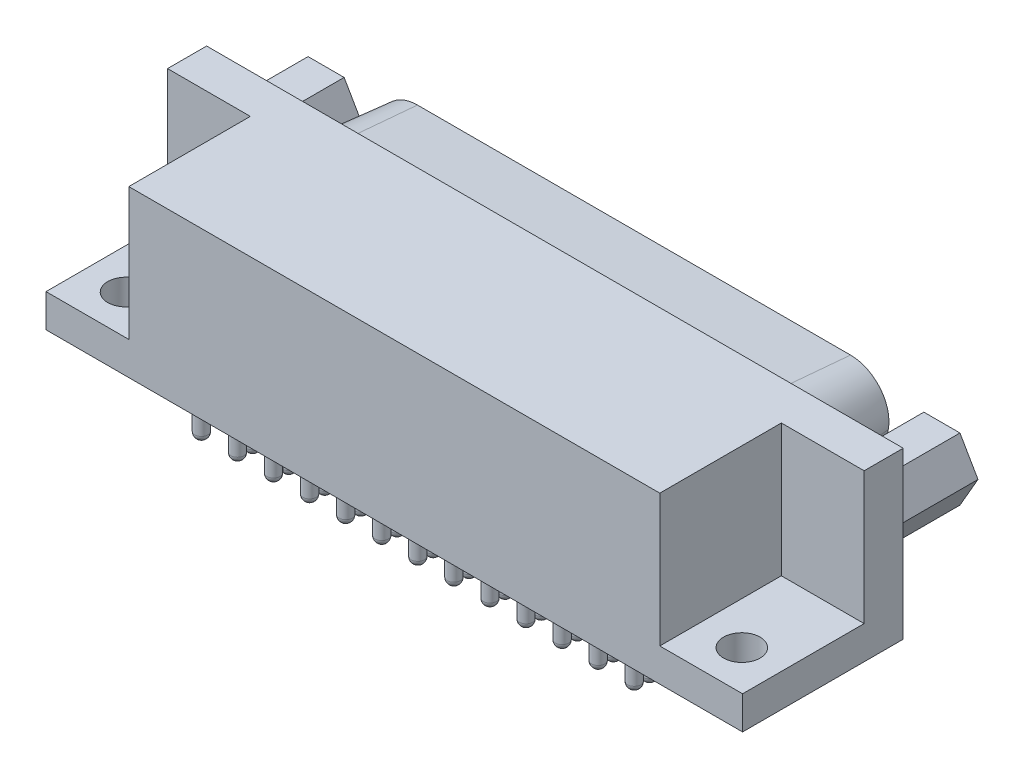
from build123d import *

# Parameters (mm, degrees)
SKETCH1_W                     = 53.47
SKETCH1_H                     = 12.33
BASE_EXTRUDE_DEPTH            = 12.7
BOSS_EXTRUDE1_DEPTH           = 6.07
BOSS_EXTRUDE1_TAPER           = 5
CUT_EXTRUDE5_DEPTH            = 6.07
CUT_EXTRUDE5_DRAFT            = 5
SKETCH6_R                     = 0.5
BOSS_EXTRUDE2_DEPTH           = 2.54
DOME3_FACE_RADIUS             = 0.5
DOME3_HEIGHT                  = 0.5
LPATTERN1_COUNT               = 13
LPATTERN1_PITCH               = 2.7686
LPATTERN1_COPY_1_FACE_RADIUS  = 0.5
LPATTERN1_COPY_1_HEIGHT       = 0.5
LPATTERN1_COPY_2_FACE_RADIUS  = 0.5
LPATTERN1_COPY_2_HEIGHT       = 0.5
LPATTERN1_COPY_3_FACE_RADIUS  = 0.5
LPATTERN1_COPY_3_HEIGHT       = 0.5
LPATTERN1_COPY_4_FACE_RADIUS  = 0.5
LPATTERN1_COPY_4_HEIGHT       = 0.5
LPATTERN1_COPY_5_FACE_RADIUS  = 0.5
LPATTERN1_COPY_5_HEIGHT       = 0.5
LPATTERN1_COPY_6_FACE_RADIUS  = 0.5
LPATTERN1_COPY_6_HEIGHT       = 0.5
LPATTERN1_COPY_7_FACE_RADIUS  = 0.5
LPATTERN1_COPY_7_HEIGHT       = 0.5
LPATTERN1_COPY_8_FACE_RADIUS  = 0.5
LPATTERN1_COPY_8_HEIGHT       = 0.5
LPATTERN1_COPY_9_FACE_RADIUS  = 0.5
LPATTERN1_COPY_9_HEIGHT       = 0.5
LPATTERN1_COPY_10_FACE_RADIUS = 0.5
LPATTERN1_COPY_10_HEIGHT      = 0.5
LPATTERN1_COPY_11_FACE_RADIUS = 0.5
LPATTERN1_COPY_11_HEIGHT      = 0.5
LPATTERN1_COPY_12_FACE_RADIUS = 0.5
LPATTERN1_COPY_12_HEIGHT      = 0.5
SKETCH7_R                     = 0.5
BOSS_EXTRUDE3_DEPTH           = 4
DOME4_FACE_RADIUS             = 0.5
DOME4_HEIGHT                  = 0.5
LPATTERN4_COUNT               = 12
LPATTERN4_PITCH               = 2.7686
LPATTERN4_COPY_1_FACE_RADIUS  = 0.5
LPATTERN4_COPY_1_HEIGHT       = 0.5
LPATTERN4_COPY_2_FACE_RADIUS  = 0.5
LPATTERN4_COPY_2_HEIGHT       = 0.5
LPATTERN4_COPY_3_FACE_RADIUS  = 0.5
LPATTERN4_COPY_3_HEIGHT       = 0.5
LPATTERN4_COPY_4_FACE_RADIUS  = 0.5
LPATTERN4_COPY_4_HEIGHT       = 0.5
LPATTERN4_COPY_5_FACE_RADIUS  = 0.5
LPATTERN4_COPY_5_HEIGHT       = 0.5
LPATTERN4_COPY_6_FACE_RADIUS  = 0.5
LPATTERN4_COPY_6_HEIGHT       = 0.5
LPATTERN4_COPY_7_FACE_RADIUS  = 0.5
LPATTERN4_COPY_7_HEIGHT       = 0.5
LPATTERN4_COPY_8_FACE_RADIUS  = 0.5
LPATTERN4_COPY_8_HEIGHT       = 0.5
LPATTERN4_COPY_9_FACE_RADIUS  = 0.5
LPATTERN4_COPY_9_HEIGHT       = 0.5
LPATTERN4_COPY_10_FACE_RADIUS = 0.5
LPATTERN4_COPY_10_HEIGHT      = 0.5
LPATTERN4_COPY_11_FACE_RADIUS = 0.5
LPATTERN4_COPY_11_HEIGHT      = 0.5
SKETCH14_R                    = 0.5
BOSS_EXTRUDE5_DEPTH           = 4
DOME1_FACE_RADIUS             = 0.5
DOME1_HEIGHT                  = 0.5
LPATTERN5_COUNT               = 13
LPATTERN5_PITCH               = 2.77
LPATTERN5_COPY_1_FACE_RADIUS  = 0.5
LPATTERN5_COPY_1_HEIGHT       = 0.5
LPATTERN5_COPY_2_FACE_RADIUS  = 0.5
LPATTERN5_COPY_2_HEIGHT       = 0.5
LPATTERN5_COPY_3_FACE_RADIUS  = 0.5
LPATTERN5_COPY_3_HEIGHT       = 0.5
LPATTERN5_COPY_4_FACE_RADIUS  = 0.5
LPATTERN5_COPY_4_HEIGHT       = 0.5
LPATTERN5_COPY_5_FACE_RADIUS  = 0.5
LPATTERN5_COPY_5_HEIGHT       = 0.5
LPATTERN5_COPY_6_FACE_RADIUS  = 0.5
LPATTERN5_COPY_6_HEIGHT       = 0.5
LPATTERN5_COPY_7_FACE_RADIUS  = 0.5
LPATTERN5_COPY_7_HEIGHT       = 0.5
LPATTERN5_COPY_8_FACE_RADIUS  = 0.5
LPATTERN5_COPY_8_HEIGHT       = 0.5
LPATTERN5_COPY_9_FACE_RADIUS  = 0.5
LPATTERN5_COPY_9_HEIGHT       = 0.5
LPATTERN5_COPY_10_FACE_RADIUS = 0.5
LPATTERN5_COPY_10_HEIGHT      = 0.5
LPATTERN5_COPY_11_FACE_RADIUS = 0.5
LPATTERN5_COPY_11_HEIGHT      = 0.5
LPATTERN5_COPY_12_FACE_RADIUS = 0.5
LPATTERN5_COPY_12_HEIGHT      = 0.5
SKETCH15_R                    = 0.5
BOSS_EXTRUDE6_DEPTH           = 4
DOME2_FACE_RADIUS             = 0.5
DOME2_HEIGHT                  = 0.5
LPATTERN6_COUNT               = 12
LPATTERN6_PITCH               = 2.77
LPATTERN6_COPY_1_FACE_RADIUS  = 0.5
LPATTERN6_COPY_1_HEIGHT       = 0.5
LPATTERN6_COPY_2_FACE_RADIUS  = 0.5
LPATTERN6_COPY_2_HEIGHT       = 0.5
LPATTERN6_COPY_3_FACE_RADIUS  = 0.5
LPATTERN6_COPY_3_HEIGHT       = 0.5
LPATTERN6_COPY_4_FACE_RADIUS  = 0.5
LPATTERN6_COPY_4_HEIGHT       = 0.5
LPATTERN6_COPY_5_FACE_RADIUS  = 0.5
LPATTERN6_COPY_5_HEIGHT       = 0.5
LPATTERN6_COPY_6_FACE_RADIUS  = 0.5
LPATTERN6_COPY_6_HEIGHT       = 0.5
LPATTERN6_COPY_7_FACE_RADIUS  = 0.5
LPATTERN6_COPY_7_HEIGHT       = 0.5
LPATTERN6_COPY_8_FACE_RADIUS  = 0.5
LPATTERN6_COPY_8_HEIGHT       = 0.5
LPATTERN6_COPY_9_FACE_RADIUS  = 0.5
LPATTERN6_COPY_9_HEIGHT       = 0.5
LPATTERN6_COPY_10_FACE_RADIUS = 0.5
LPATTERN6_COPY_10_HEIGHT      = 0.5
LPATTERN6_COPY_11_FACE_RADIUS = 0.5
LPATTERN6_COPY_11_HEIGHT      = 0.5
SKETCH12_R                    = 1.304277921
BOSS_EXTRUDE4_DEPTH           = 6.07
SKETCH9_W                     = 6.35508
SKETCH9_H                     = 10.16
CUT_EXTRUDE3_DEPTH            = 9.33
SKETCH11_R                    = 1.4
CUT_EXTRUDE4_DEPTH            = 48.492511024


with BuildPart() as part:
    # Sketch1 → Base-Extrude (new body)
    with BuildSketch(Plane(origin=(0, 0, 0), x_dir=(1, 0, 0), z_dir=(0, 1, 0))):
        with Locations((16.575, 4.395)):
            Rectangle(SKETCH1_W, SKETCH1_H)
    extrude(amount=BASE_EXTRUDE_DEPTH)

    # Sketch2 → Boss-Extrude1 (add)
    with BuildSketch(Plane(origin=(0, 0, -10.56), x_dir=(-1, 0, 0), z_dir=(0, 0, -1))):
        with BuildLine():
            Line((-32.614575524, 1.37), (-0.535424476, 1.37))
            ThreePointArc((-0.535424476, 1.37), (1.679299183, 2.16571255), (2.881216284, 4.188966026))
            Line((2.881216284, 4.188966026), (3.46164076, 7.188966026))
            ThreePointArc((3.46164076, 7.188966026), (2.72928745, 10.064723659), (0.045, 11.33))
            Line((0.045, 11.33), (-33.195, 11.33))
            ThreePointArc((-33.195, 11.33), (-35.87928745, 10.064723659), (-36.61164076, 7.188966026))
            Line((-36.61164076, 7.188966026), (-36.031216284, 4.188966026))
            ThreePointArc((-36.031216284, 4.188966026), (-34.829299183, 2.16571255), (-32.614575524, 1.37))
        make_face()
    extrude(amount=BOSS_EXTRUDE1_DEPTH, taper=BOSS_EXTRUDE1_TAPER)


with BuildPart() as cut_extrude5_tool:
    # Sketch13 → Cut-Extrude5 (with draft: the straight prism first)
    with BuildSketch(Plane(origin=(0, 0, -16.63), x_dir=(-1, 0, 0), z_dir=(0, 0, -1))):
        with BuildLine():
            Line((1.967111537, 4.365822282), (2.547536013, 7.365822282))
            ThreePointArc((2.547536013, 7.365822282), (2.011120082, 9.47218568), (0.045, 10.398943812))
            Line((0.045, 10.398943812), (-33.195, 10.398943812))
            ThreePointArc((-33.195, 10.398943812), (-35.161120082, 9.47218568), (-35.697536013, 7.365822282))
            Line((-35.697536013, 7.365822282), (-35.117111537, 4.365822282))
            ThreePointArc((-35.117111537, 4.365822282), (-34.236761204, 2.883879918), (-32.614575524, 2.301056188))
            Line((-32.614575524, 2.301056188), (-0.535424476, 2.301056188))
            ThreePointArc((-0.535424476, 2.301056188), (1.086761204, 2.883879918), (1.967111537, 4.365822282))
        make_face()
    extrude(amount=-CUT_EXTRUDE5_DEPTH)
    # Cut-Extrude5: the draft: its side faces are tilted about the plane it starts from
    cut_extrude5_sides = [cut_extrude5_tool.faces().sort_by_distance(p)[0] for p in [
        (16.575, 2.301056188, -13.595),
        (-1.086761204, 2.883879918, -13.595),
        (-2.257323775, 5.865822282, -13.595),
        (-2.011120082, 9.47218568, -13.595),
        (16.575, 10.398943812, -13.595),
        (35.161120082, 9.47218568, -13.595),
        (35.407323775, 5.865822282, -13.595),
        (34.236761204, 2.883879918, -13.595),
    ]]
    draft(cut_extrude5_sides, Plane(origin=(0, 0, -16.63), x_dir=(-1, 0, 0), z_dir=(0, 0, -1)), CUT_EXTRUDE5_DRAFT)


with BuildPart() as part_1:
    add(part.part)

    # Cut-Extrude5: cut by cut_extrude5_tool
    add(cut_extrude5_tool.part, mode=Mode.SUBTRACT)

    # Sketch6 → Boss-Extrude2 (add)
    with BuildSketch(Plane.XZ):
        with Locations(Location((0, 0, 0), (0, 0, 270))):
            Circle(SKETCH6_R)
    boss_extrude2 = extrude(amount=BOSS_EXTRUDE2_DEPTH)

    # Dome3: a dome of height H over a round flat face of radius A is a cap of a sphere of radius (A * A + H * H) / (2 * H)
    dome3_r = (DOME3_FACE_RADIUS * DOME3_FACE_RADIUS + DOME3_HEIGHT * DOME3_HEIGHT) / (2 * DOME3_HEIGHT)
    dome3_base = Plane((0, -2.54, 0), z_dir=(0, -1, 0))
    with Locations(dome3_base.offset(DOME3_HEIGHT - dome3_r)):
        dome3_ball = Sphere(dome3_r, mode=Mode.PRIVATE)
    add(split(dome3_ball, bisect_by=dome3_base, keep=Keep.TOP, mode=Mode.PRIVATE))

    # LPattern1: Boss-Extrude2 ×13
    with Locations(*[(i * LPATTERN1_PITCH, 0, 0) for i in range(1, LPATTERN1_COUNT)]):
        add(boss_extrude2)

    # LPattern1 copy 1: a dome of height H over a round flat face of radius A is a cap of a sphere of radius (A * A + H * H) / (2 * H)
    lpattern1_copy_1_r = (LPATTERN1_COPY_1_FACE_RADIUS * LPATTERN1_COPY_1_FACE_RADIUS + LPATTERN1_COPY_1_HEIGHT * LPATTERN1_COPY_1_HEIGHT) / (2 * LPATTERN1_COPY_1_HEIGHT)
    lpattern1_copy_1_base = Plane((2.7686, -2.54, 0), z_dir=(0, -1, 0))
    with Locations(lpattern1_copy_1_base.offset(LPATTERN1_COPY_1_HEIGHT - lpattern1_copy_1_r)):
        lpattern1_copy_1_ball = Sphere(lpattern1_copy_1_r, mode=Mode.PRIVATE)
    add(split(lpattern1_copy_1_ball, bisect_by=lpattern1_copy_1_base, keep=Keep.TOP, mode=Mode.PRIVATE))

    # LPattern1 copy 2: a dome of height H over a round flat face of radius A is a cap of a sphere of radius (A * A + H * H) / (2 * H)
    lpattern1_copy_2_r = (LPATTERN1_COPY_2_FACE_RADIUS * LPATTERN1_COPY_2_FACE_RADIUS + LPATTERN1_COPY_2_HEIGHT * LPATTERN1_COPY_2_HEIGHT) / (2 * LPATTERN1_COPY_2_HEIGHT)
    lpattern1_copy_2_base = Plane((5.5372, -2.54, 0), z_dir=(0, -1, 0))
    with Locations(lpattern1_copy_2_base.offset(LPATTERN1_COPY_2_HEIGHT - lpattern1_copy_2_r)):
        lpattern1_copy_2_ball = Sphere(lpattern1_copy_2_r, mode=Mode.PRIVATE)
    add(split(lpattern1_copy_2_ball, bisect_by=lpattern1_copy_2_base, keep=Keep.TOP, mode=Mode.PRIVATE))

    # LPattern1 copy 3: a dome of height H over a round flat face of radius A is a cap of a sphere of radius (A * A + H * H) / (2 * H)
    lpattern1_copy_3_r = (LPATTERN1_COPY_3_FACE_RADIUS * LPATTERN1_COPY_3_FACE_RADIUS + LPATTERN1_COPY_3_HEIGHT * LPATTERN1_COPY_3_HEIGHT) / (2 * LPATTERN1_COPY_3_HEIGHT)
    lpattern1_copy_3_base = Plane((8.3058, -2.54, 0), z_dir=(0, -1, 0))
    with Locations(lpattern1_copy_3_base.offset(LPATTERN1_COPY_3_HEIGHT - lpattern1_copy_3_r)):
        lpattern1_copy_3_ball = Sphere(lpattern1_copy_3_r, mode=Mode.PRIVATE)
    add(split(lpattern1_copy_3_ball, bisect_by=lpattern1_copy_3_base, keep=Keep.TOP, mode=Mode.PRIVATE))

    # LPattern1 copy 4: a dome of height H over a round flat face of radius A is a cap of a sphere of radius (A * A + H * H) / (2 * H)
    lpattern1_copy_4_r = (LPATTERN1_COPY_4_FACE_RADIUS * LPATTERN1_COPY_4_FACE_RADIUS + LPATTERN1_COPY_4_HEIGHT * LPATTERN1_COPY_4_HEIGHT) / (2 * LPATTERN1_COPY_4_HEIGHT)
    lpattern1_copy_4_base = Plane((11.0744, -2.54, 0), z_dir=(0, -1, 0))
    with Locations(lpattern1_copy_4_base.offset(LPATTERN1_COPY_4_HEIGHT - lpattern1_copy_4_r)):
        lpattern1_copy_4_ball = Sphere(lpattern1_copy_4_r, mode=Mode.PRIVATE)
    add(split(lpattern1_copy_4_ball, bisect_by=lpattern1_copy_4_base, keep=Keep.TOP, mode=Mode.PRIVATE))

    # LPattern1 copy 5: a dome of height H over a round flat face of radius A is a cap of a sphere of radius (A * A + H * H) / (2 * H)
    lpattern1_copy_5_r = (LPATTERN1_COPY_5_FACE_RADIUS * LPATTERN1_COPY_5_FACE_RADIUS + LPATTERN1_COPY_5_HEIGHT * LPATTERN1_COPY_5_HEIGHT) / (2 * LPATTERN1_COPY_5_HEIGHT)
    lpattern1_copy_5_base = Plane((13.843, -2.54, 0), z_dir=(0, -1, 0))
    with Locations(lpattern1_copy_5_base.offset(LPATTERN1_COPY_5_HEIGHT - lpattern1_copy_5_r)):
        lpattern1_copy_5_ball = Sphere(lpattern1_copy_5_r, mode=Mode.PRIVATE)
    add(split(lpattern1_copy_5_ball, bisect_by=lpattern1_copy_5_base, keep=Keep.TOP, mode=Mode.PRIVATE))

    # LPattern1 copy 6: a dome of height H over a round flat face of radius A is a cap of a sphere of radius (A * A + H * H) / (2 * H)
    lpattern1_copy_6_r = (LPATTERN1_COPY_6_FACE_RADIUS * LPATTERN1_COPY_6_FACE_RADIUS + LPATTERN1_COPY_6_HEIGHT * LPATTERN1_COPY_6_HEIGHT) / (2 * LPATTERN1_COPY_6_HEIGHT)
    lpattern1_copy_6_base = Plane((16.6116, -2.54, 0), z_dir=(0, -1, 0))
    with Locations(lpattern1_copy_6_base.offset(LPATTERN1_COPY_6_HEIGHT - lpattern1_copy_6_r)):
        lpattern1_copy_6_ball = Sphere(lpattern1_copy_6_r, mode=Mode.PRIVATE)
    add(split(lpattern1_copy_6_ball, bisect_by=lpattern1_copy_6_base, keep=Keep.TOP, mode=Mode.PRIVATE))

    # LPattern1 copy 7: a dome of height H over a round flat face of radius A is a cap of a sphere of radius (A * A + H * H) / (2 * H)
    lpattern1_copy_7_r = (LPATTERN1_COPY_7_FACE_RADIUS * LPATTERN1_COPY_7_FACE_RADIUS + LPATTERN1_COPY_7_HEIGHT * LPATTERN1_COPY_7_HEIGHT) / (2 * LPATTERN1_COPY_7_HEIGHT)
    lpattern1_copy_7_base = Plane((19.3802, -2.54, 0), z_dir=(0, -1, 0))
    with Locations(lpattern1_copy_7_base.offset(LPATTERN1_COPY_7_HEIGHT - lpattern1_copy_7_r)):
        lpattern1_copy_7_ball = Sphere(lpattern1_copy_7_r, mode=Mode.PRIVATE)
    add(split(lpattern1_copy_7_ball, bisect_by=lpattern1_copy_7_base, keep=Keep.TOP, mode=Mode.PRIVATE))

    # LPattern1 copy 8: a dome of height H over a round flat face of radius A is a cap of a sphere of radius (A * A + H * H) / (2 * H)
    lpattern1_copy_8_r = (LPATTERN1_COPY_8_FACE_RADIUS * LPATTERN1_COPY_8_FACE_RADIUS + LPATTERN1_COPY_8_HEIGHT * LPATTERN1_COPY_8_HEIGHT) / (2 * LPATTERN1_COPY_8_HEIGHT)
    lpattern1_copy_8_base = Plane((22.1488, -2.54, 0), z_dir=(0, -1, 0))
    with Locations(lpattern1_copy_8_base.offset(LPATTERN1_COPY_8_HEIGHT - lpattern1_copy_8_r)):
        lpattern1_copy_8_ball = Sphere(lpattern1_copy_8_r, mode=Mode.PRIVATE)
    add(split(lpattern1_copy_8_ball, bisect_by=lpattern1_copy_8_base, keep=Keep.TOP, mode=Mode.PRIVATE))

    # LPattern1 copy 9: a dome of height H over a round flat face of radius A is a cap of a sphere of radius (A * A + H * H) / (2 * H)
    lpattern1_copy_9_r = (LPATTERN1_COPY_9_FACE_RADIUS * LPATTERN1_COPY_9_FACE_RADIUS + LPATTERN1_COPY_9_HEIGHT * LPATTERN1_COPY_9_HEIGHT) / (2 * LPATTERN1_COPY_9_HEIGHT)
    lpattern1_copy_9_base = Plane((24.9174, -2.54, 0), z_dir=(0, -1, 0))
    with Locations(lpattern1_copy_9_base.offset(LPATTERN1_COPY_9_HEIGHT - lpattern1_copy_9_r)):
        lpattern1_copy_9_ball = Sphere(lpattern1_copy_9_r, mode=Mode.PRIVATE)
    add(split(lpattern1_copy_9_ball, bisect_by=lpattern1_copy_9_base, keep=Keep.TOP, mode=Mode.PRIVATE))

    # LPattern1 copy 10: a dome of height H over a round flat face of radius A is a cap of a sphere of radius (A * A + H * H) / (2 * H)
    lpattern1_copy_10_r = (LPATTERN1_COPY_10_FACE_RADIUS * LPATTERN1_COPY_10_FACE_RADIUS + LPATTERN1_COPY_10_HEIGHT * LPATTERN1_COPY_10_HEIGHT) / (2 * LPATTERN1_COPY_10_HEIGHT)
    lpattern1_copy_10_base = Plane((27.686, -2.54, 0), z_dir=(0, -1, 0))
    with Locations(lpattern1_copy_10_base.offset(LPATTERN1_COPY_10_HEIGHT - lpattern1_copy_10_r)):
        lpattern1_copy_10_ball = Sphere(lpattern1_copy_10_r, mode=Mode.PRIVATE)
    add(split(lpattern1_copy_10_ball, bisect_by=lpattern1_copy_10_base, keep=Keep.TOP, mode=Mode.PRIVATE))

    # LPattern1 copy 11: a dome of height H over a round flat face of radius A is a cap of a sphere of radius (A * A + H * H) / (2 * H)
    lpattern1_copy_11_r = (LPATTERN1_COPY_11_FACE_RADIUS * LPATTERN1_COPY_11_FACE_RADIUS + LPATTERN1_COPY_11_HEIGHT * LPATTERN1_COPY_11_HEIGHT) / (2 * LPATTERN1_COPY_11_HEIGHT)
    lpattern1_copy_11_base = Plane((30.4546, -2.54, 0), z_dir=(0, -1, 0))
    with Locations(lpattern1_copy_11_base.offset(LPATTERN1_COPY_11_HEIGHT - lpattern1_copy_11_r)):
        lpattern1_copy_11_ball = Sphere(lpattern1_copy_11_r, mode=Mode.PRIVATE)
    add(split(lpattern1_copy_11_ball, bisect_by=lpattern1_copy_11_base, keep=Keep.TOP, mode=Mode.PRIVATE))

    # LPattern1 copy 12: a dome of height H over a round flat face of radius A is a cap of a sphere of radius (A * A + H * H) / (2 * H)
    lpattern1_copy_12_r = (LPATTERN1_COPY_12_FACE_RADIUS * LPATTERN1_COPY_12_FACE_RADIUS + LPATTERN1_COPY_12_HEIGHT * LPATTERN1_COPY_12_HEIGHT) / (2 * LPATTERN1_COPY_12_HEIGHT)
    lpattern1_copy_12_base = Plane((33.2232, -2.54, 0), z_dir=(0, -1, 0))
    with Locations(lpattern1_copy_12_base.offset(LPATTERN1_COPY_12_HEIGHT - lpattern1_copy_12_r)):
        lpattern1_copy_12_ball = Sphere(lpattern1_copy_12_r, mode=Mode.PRIVATE)
    add(split(lpattern1_copy_12_ball, bisect_by=lpattern1_copy_12_base, keep=Keep.TOP, mode=Mode.PRIVATE))

    # Sketch7 → Boss-Extrude3 (add)
    with BuildSketch(Plane.XZ):
        with Locations(Location((1.397, -2.54, 0), (0, 0, 270))):
            Circle(SKETCH7_R)
    boss_extrude3 = extrude(amount=BOSS_EXTRUDE3_DEPTH)

    # Dome4: a dome of height H over a round flat face of radius A is a cap of a sphere of radius (A * A + H * H) / (2 * H)
    dome4_r = (DOME4_FACE_RADIUS * DOME4_FACE_RADIUS + DOME4_HEIGHT * DOME4_HEIGHT) / (2 * DOME4_HEIGHT)
    dome4_base = Plane((1.397, -4, -2.54), z_dir=(0, -1, 0))
    with Locations(dome4_base.offset(DOME4_HEIGHT - dome4_r)):
        dome4_ball = Sphere(dome4_r, mode=Mode.PRIVATE)
    add(split(dome4_ball, bisect_by=dome4_base, keep=Keep.TOP, mode=Mode.PRIVATE))

    # LPattern4: Boss-Extrude3 ×12
    with Locations(*[(i * LPATTERN4_PITCH, 0, 0) for i in range(1, LPATTERN4_COUNT)]):
        add(boss_extrude3)

    # LPattern4 copy 1: a dome of height H over a round flat face of radius A is a cap of a sphere of radius (A * A + H * H) / (2 * H)
    lpattern4_copy_1_r = (LPATTERN4_COPY_1_FACE_RADIUS * LPATTERN4_COPY_1_FACE_RADIUS + LPATTERN4_COPY_1_HEIGHT * LPATTERN4_COPY_1_HEIGHT) / (2 * LPATTERN4_COPY_1_HEIGHT)
    lpattern4_copy_1_base = Plane((4.1656, -4, -2.54), z_dir=(0, -1, 0))
    with Locations(lpattern4_copy_1_base.offset(LPATTERN4_COPY_1_HEIGHT - lpattern4_copy_1_r)):
        lpattern4_copy_1_ball = Sphere(lpattern4_copy_1_r, mode=Mode.PRIVATE)
    add(split(lpattern4_copy_1_ball, bisect_by=lpattern4_copy_1_base, keep=Keep.TOP, mode=Mode.PRIVATE))

    # LPattern4 copy 2: a dome of height H over a round flat face of radius A is a cap of a sphere of radius (A * A + H * H) / (2 * H)
    lpattern4_copy_2_r = (LPATTERN4_COPY_2_FACE_RADIUS * LPATTERN4_COPY_2_FACE_RADIUS + LPATTERN4_COPY_2_HEIGHT * LPATTERN4_COPY_2_HEIGHT) / (2 * LPATTERN4_COPY_2_HEIGHT)
    lpattern4_copy_2_base = Plane((6.9342, -4, -2.54), z_dir=(0, -1, 0))
    with Locations(lpattern4_copy_2_base.offset(LPATTERN4_COPY_2_HEIGHT - lpattern4_copy_2_r)):
        lpattern4_copy_2_ball = Sphere(lpattern4_copy_2_r, mode=Mode.PRIVATE)
    add(split(lpattern4_copy_2_ball, bisect_by=lpattern4_copy_2_base, keep=Keep.TOP, mode=Mode.PRIVATE))

    # LPattern4 copy 3: a dome of height H over a round flat face of radius A is a cap of a sphere of radius (A * A + H * H) / (2 * H)
    lpattern4_copy_3_r = (LPATTERN4_COPY_3_FACE_RADIUS * LPATTERN4_COPY_3_FACE_RADIUS + LPATTERN4_COPY_3_HEIGHT * LPATTERN4_COPY_3_HEIGHT) / (2 * LPATTERN4_COPY_3_HEIGHT)
    lpattern4_copy_3_base = Plane((9.7028, -4, -2.54), z_dir=(0, -1, 0))
    with Locations(lpattern4_copy_3_base.offset(LPATTERN4_COPY_3_HEIGHT - lpattern4_copy_3_r)):
        lpattern4_copy_3_ball = Sphere(lpattern4_copy_3_r, mode=Mode.PRIVATE)
    add(split(lpattern4_copy_3_ball, bisect_by=lpattern4_copy_3_base, keep=Keep.TOP, mode=Mode.PRIVATE))

    # LPattern4 copy 4: a dome of height H over a round flat face of radius A is a cap of a sphere of radius (A * A + H * H) / (2 * H)
    lpattern4_copy_4_r = (LPATTERN4_COPY_4_FACE_RADIUS * LPATTERN4_COPY_4_FACE_RADIUS + LPATTERN4_COPY_4_HEIGHT * LPATTERN4_COPY_4_HEIGHT) / (2 * LPATTERN4_COPY_4_HEIGHT)
    lpattern4_copy_4_base = Plane((12.4714, -4, -2.54), z_dir=(0, -1, 0))
    with Locations(lpattern4_copy_4_base.offset(LPATTERN4_COPY_4_HEIGHT - lpattern4_copy_4_r)):
        lpattern4_copy_4_ball = Sphere(lpattern4_copy_4_r, mode=Mode.PRIVATE)
    add(split(lpattern4_copy_4_ball, bisect_by=lpattern4_copy_4_base, keep=Keep.TOP, mode=Mode.PRIVATE))

    # LPattern4 copy 5: a dome of height H over a round flat face of radius A is a cap of a sphere of radius (A * A + H * H) / (2 * H)
    lpattern4_copy_5_r = (LPATTERN4_COPY_5_FACE_RADIUS * LPATTERN4_COPY_5_FACE_RADIUS + LPATTERN4_COPY_5_HEIGHT * LPATTERN4_COPY_5_HEIGHT) / (2 * LPATTERN4_COPY_5_HEIGHT)
    lpattern4_copy_5_base = Plane((15.24, -4, -2.54), z_dir=(0, -1, 0))
    with Locations(lpattern4_copy_5_base.offset(LPATTERN4_COPY_5_HEIGHT - lpattern4_copy_5_r)):
        lpattern4_copy_5_ball = Sphere(lpattern4_copy_5_r, mode=Mode.PRIVATE)
    add(split(lpattern4_copy_5_ball, bisect_by=lpattern4_copy_5_base, keep=Keep.TOP, mode=Mode.PRIVATE))

    # LPattern4 copy 6: a dome of height H over a round flat face of radius A is a cap of a sphere of radius (A * A + H * H) / (2 * H)
    lpattern4_copy_6_r = (LPATTERN4_COPY_6_FACE_RADIUS * LPATTERN4_COPY_6_FACE_RADIUS + LPATTERN4_COPY_6_HEIGHT * LPATTERN4_COPY_6_HEIGHT) / (2 * LPATTERN4_COPY_6_HEIGHT)
    lpattern4_copy_6_base = Plane((18.0086, -4, -2.54), z_dir=(0, -1, 0))
    with Locations(lpattern4_copy_6_base.offset(LPATTERN4_COPY_6_HEIGHT - lpattern4_copy_6_r)):
        lpattern4_copy_6_ball = Sphere(lpattern4_copy_6_r, mode=Mode.PRIVATE)
    add(split(lpattern4_copy_6_ball, bisect_by=lpattern4_copy_6_base, keep=Keep.TOP, mode=Mode.PRIVATE))

    # LPattern4 copy 7: a dome of height H over a round flat face of radius A is a cap of a sphere of radius (A * A + H * H) / (2 * H)
    lpattern4_copy_7_r = (LPATTERN4_COPY_7_FACE_RADIUS * LPATTERN4_COPY_7_FACE_RADIUS + LPATTERN4_COPY_7_HEIGHT * LPATTERN4_COPY_7_HEIGHT) / (2 * LPATTERN4_COPY_7_HEIGHT)
    lpattern4_copy_7_base = Plane((20.7772, -4, -2.54), z_dir=(0, -1, 0))
    with Locations(lpattern4_copy_7_base.offset(LPATTERN4_COPY_7_HEIGHT - lpattern4_copy_7_r)):
        lpattern4_copy_7_ball = Sphere(lpattern4_copy_7_r, mode=Mode.PRIVATE)
    add(split(lpattern4_copy_7_ball, bisect_by=lpattern4_copy_7_base, keep=Keep.TOP, mode=Mode.PRIVATE))

    # LPattern4 copy 8: a dome of height H over a round flat face of radius A is a cap of a sphere of radius (A * A + H * H) / (2 * H)
    lpattern4_copy_8_r = (LPATTERN4_COPY_8_FACE_RADIUS * LPATTERN4_COPY_8_FACE_RADIUS + LPATTERN4_COPY_8_HEIGHT * LPATTERN4_COPY_8_HEIGHT) / (2 * LPATTERN4_COPY_8_HEIGHT)
    lpattern4_copy_8_base = Plane((23.5458, -4, -2.54), z_dir=(0, -1, 0))
    with Locations(lpattern4_copy_8_base.offset(LPATTERN4_COPY_8_HEIGHT - lpattern4_copy_8_r)):
        lpattern4_copy_8_ball = Sphere(lpattern4_copy_8_r, mode=Mode.PRIVATE)
    add(split(lpattern4_copy_8_ball, bisect_by=lpattern4_copy_8_base, keep=Keep.TOP, mode=Mode.PRIVATE))

    # LPattern4 copy 9: a dome of height H over a round flat face of radius A is a cap of a sphere of radius (A * A + H * H) / (2 * H)
    lpattern4_copy_9_r = (LPATTERN4_COPY_9_FACE_RADIUS * LPATTERN4_COPY_9_FACE_RADIUS + LPATTERN4_COPY_9_HEIGHT * LPATTERN4_COPY_9_HEIGHT) / (2 * LPATTERN4_COPY_9_HEIGHT)
    lpattern4_copy_9_base = Plane((26.3144, -4, -2.54), z_dir=(0, -1, 0))
    with Locations(lpattern4_copy_9_base.offset(LPATTERN4_COPY_9_HEIGHT - lpattern4_copy_9_r)):
        lpattern4_copy_9_ball = Sphere(lpattern4_copy_9_r, mode=Mode.PRIVATE)
    add(split(lpattern4_copy_9_ball, bisect_by=lpattern4_copy_9_base, keep=Keep.TOP, mode=Mode.PRIVATE))

    # LPattern4 copy 10: a dome of height H over a round flat face of radius A is a cap of a sphere of radius (A * A + H * H) / (2 * H)
    lpattern4_copy_10_r = (LPATTERN4_COPY_10_FACE_RADIUS * LPATTERN4_COPY_10_FACE_RADIUS + LPATTERN4_COPY_10_HEIGHT * LPATTERN4_COPY_10_HEIGHT) / (2 * LPATTERN4_COPY_10_HEIGHT)
    lpattern4_copy_10_base = Plane((29.083, -4, -2.54), z_dir=(0, -1, 0))
    with Locations(lpattern4_copy_10_base.offset(LPATTERN4_COPY_10_HEIGHT - lpattern4_copy_10_r)):
        lpattern4_copy_10_ball = Sphere(lpattern4_copy_10_r, mode=Mode.PRIVATE)
    add(split(lpattern4_copy_10_ball, bisect_by=lpattern4_copy_10_base, keep=Keep.TOP, mode=Mode.PRIVATE))

    # LPattern4 copy 11: a dome of height H over a round flat face of radius A is a cap of a sphere of radius (A * A + H * H) / (2 * H)
    lpattern4_copy_11_r = (LPATTERN4_COPY_11_FACE_RADIUS * LPATTERN4_COPY_11_FACE_RADIUS + LPATTERN4_COPY_11_HEIGHT * LPATTERN4_COPY_11_HEIGHT) / (2 * LPATTERN4_COPY_11_HEIGHT)
    lpattern4_copy_11_base = Plane((31.8516, -4, -2.54), z_dir=(0, -1, 0))
    with Locations(lpattern4_copy_11_base.offset(LPATTERN4_COPY_11_HEIGHT - lpattern4_copy_11_r)):
        lpattern4_copy_11_ball = Sphere(lpattern4_copy_11_r, mode=Mode.PRIVATE)
    add(split(lpattern4_copy_11_ball, bisect_by=lpattern4_copy_11_base, keep=Keep.TOP, mode=Mode.PRIVATE))

    # Sketch14 → Boss-Extrude5 (add)
    with BuildSketch(Plane(origin=(0, 0, -10.56), x_dir=(-1, 0, 0), z_dir=(0, 0, -1))):
        with Locations((0.045, 7.85)):
            Circle(SKETCH14_R)
    boss_extrude5 = extrude(amount=BOSS_EXTRUDE5_DEPTH)

    # Dome1: a dome of height H over a round flat face of radius A is a cap of a sphere of radius (A * A + H * H) / (2 * H)
    dome1_r = (DOME1_FACE_RADIUS * DOME1_FACE_RADIUS + DOME1_HEIGHT * DOME1_HEIGHT) / (2 * DOME1_HEIGHT)
    dome1_base = Plane((-0.045, 7.85, -14.56), z_dir=(0, 0, -1))
    with Locations(dome1_base.offset(DOME1_HEIGHT - dome1_r)):
        dome1_ball = Sphere(dome1_r, mode=Mode.PRIVATE)
    add(split(dome1_ball, bisect_by=dome1_base, keep=Keep.TOP, mode=Mode.PRIVATE))

    # LPattern5: Boss-Extrude5 ×13
    with Locations(*[(i * LPATTERN5_PITCH, 0, 0) for i in range(1, LPATTERN5_COUNT)]):
        add(boss_extrude5)

    # LPattern5 copy 1: a dome of height H over a round flat face of radius A is a cap of a sphere of radius (A * A + H * H) / (2 * H)
    lpattern5_copy_1_r = (LPATTERN5_COPY_1_FACE_RADIUS * LPATTERN5_COPY_1_FACE_RADIUS + LPATTERN5_COPY_1_HEIGHT * LPATTERN5_COPY_1_HEIGHT) / (2 * LPATTERN5_COPY_1_HEIGHT)
    lpattern5_copy_1_base = Plane((2.725, 7.85, -14.56), z_dir=(0, 0, -1))
    with Locations(lpattern5_copy_1_base.offset(LPATTERN5_COPY_1_HEIGHT - lpattern5_copy_1_r)):
        lpattern5_copy_1_ball = Sphere(lpattern5_copy_1_r, mode=Mode.PRIVATE)
    add(split(lpattern5_copy_1_ball, bisect_by=lpattern5_copy_1_base, keep=Keep.TOP, mode=Mode.PRIVATE))

    # LPattern5 copy 2: a dome of height H over a round flat face of radius A is a cap of a sphere of radius (A * A + H * H) / (2 * H)
    lpattern5_copy_2_r = (LPATTERN5_COPY_2_FACE_RADIUS * LPATTERN5_COPY_2_FACE_RADIUS + LPATTERN5_COPY_2_HEIGHT * LPATTERN5_COPY_2_HEIGHT) / (2 * LPATTERN5_COPY_2_HEIGHT)
    lpattern5_copy_2_base = Plane((5.495, 7.85, -14.56), z_dir=(0, 0, -1))
    with Locations(lpattern5_copy_2_base.offset(LPATTERN5_COPY_2_HEIGHT - lpattern5_copy_2_r)):
        lpattern5_copy_2_ball = Sphere(lpattern5_copy_2_r, mode=Mode.PRIVATE)
    add(split(lpattern5_copy_2_ball, bisect_by=lpattern5_copy_2_base, keep=Keep.TOP, mode=Mode.PRIVATE))

    # LPattern5 copy 3: a dome of height H over a round flat face of radius A is a cap of a sphere of radius (A * A + H * H) / (2 * H)
    lpattern5_copy_3_r = (LPATTERN5_COPY_3_FACE_RADIUS * LPATTERN5_COPY_3_FACE_RADIUS + LPATTERN5_COPY_3_HEIGHT * LPATTERN5_COPY_3_HEIGHT) / (2 * LPATTERN5_COPY_3_HEIGHT)
    lpattern5_copy_3_base = Plane((8.265, 7.85, -14.56), z_dir=(0, 0, -1))
    with Locations(lpattern5_copy_3_base.offset(LPATTERN5_COPY_3_HEIGHT - lpattern5_copy_3_r)):
        lpattern5_copy_3_ball = Sphere(lpattern5_copy_3_r, mode=Mode.PRIVATE)
    add(split(lpattern5_copy_3_ball, bisect_by=lpattern5_copy_3_base, keep=Keep.TOP, mode=Mode.PRIVATE))

    # LPattern5 copy 4: a dome of height H over a round flat face of radius A is a cap of a sphere of radius (A * A + H * H) / (2 * H)
    lpattern5_copy_4_r = (LPATTERN5_COPY_4_FACE_RADIUS * LPATTERN5_COPY_4_FACE_RADIUS + LPATTERN5_COPY_4_HEIGHT * LPATTERN5_COPY_4_HEIGHT) / (2 * LPATTERN5_COPY_4_HEIGHT)
    lpattern5_copy_4_base = Plane((11.035, 7.85, -14.56), z_dir=(0, 0, -1))
    with Locations(lpattern5_copy_4_base.offset(LPATTERN5_COPY_4_HEIGHT - lpattern5_copy_4_r)):
        lpattern5_copy_4_ball = Sphere(lpattern5_copy_4_r, mode=Mode.PRIVATE)
    add(split(lpattern5_copy_4_ball, bisect_by=lpattern5_copy_4_base, keep=Keep.TOP, mode=Mode.PRIVATE))

    # LPattern5 copy 5: a dome of height H over a round flat face of radius A is a cap of a sphere of radius (A * A + H * H) / (2 * H)
    lpattern5_copy_5_r = (LPATTERN5_COPY_5_FACE_RADIUS * LPATTERN5_COPY_5_FACE_RADIUS + LPATTERN5_COPY_5_HEIGHT * LPATTERN5_COPY_5_HEIGHT) / (2 * LPATTERN5_COPY_5_HEIGHT)
    lpattern5_copy_5_base = Plane((13.805, 7.85, -14.56), z_dir=(0, 0, -1))
    with Locations(lpattern5_copy_5_base.offset(LPATTERN5_COPY_5_HEIGHT - lpattern5_copy_5_r)):
        lpattern5_copy_5_ball = Sphere(lpattern5_copy_5_r, mode=Mode.PRIVATE)
    add(split(lpattern5_copy_5_ball, bisect_by=lpattern5_copy_5_base, keep=Keep.TOP, mode=Mode.PRIVATE))

    # LPattern5 copy 6: a dome of height H over a round flat face of radius A is a cap of a sphere of radius (A * A + H * H) / (2 * H)
    lpattern5_copy_6_r = (LPATTERN5_COPY_6_FACE_RADIUS * LPATTERN5_COPY_6_FACE_RADIUS + LPATTERN5_COPY_6_HEIGHT * LPATTERN5_COPY_6_HEIGHT) / (2 * LPATTERN5_COPY_6_HEIGHT)
    lpattern5_copy_6_base = Plane((16.575, 7.85, -14.56), z_dir=(0, 0, -1))
    with Locations(lpattern5_copy_6_base.offset(LPATTERN5_COPY_6_HEIGHT - lpattern5_copy_6_r)):
        lpattern5_copy_6_ball = Sphere(lpattern5_copy_6_r, mode=Mode.PRIVATE)
    add(split(lpattern5_copy_6_ball, bisect_by=lpattern5_copy_6_base, keep=Keep.TOP, mode=Mode.PRIVATE))

    # LPattern5 copy 7: a dome of height H over a round flat face of radius A is a cap of a sphere of radius (A * A + H * H) / (2 * H)
    lpattern5_copy_7_r = (LPATTERN5_COPY_7_FACE_RADIUS * LPATTERN5_COPY_7_FACE_RADIUS + LPATTERN5_COPY_7_HEIGHT * LPATTERN5_COPY_7_HEIGHT) / (2 * LPATTERN5_COPY_7_HEIGHT)
    lpattern5_copy_7_base = Plane((19.345, 7.85, -14.56), z_dir=(0, 0, -1))
    with Locations(lpattern5_copy_7_base.offset(LPATTERN5_COPY_7_HEIGHT - lpattern5_copy_7_r)):
        lpattern5_copy_7_ball = Sphere(lpattern5_copy_7_r, mode=Mode.PRIVATE)
    add(split(lpattern5_copy_7_ball, bisect_by=lpattern5_copy_7_base, keep=Keep.TOP, mode=Mode.PRIVATE))

    # LPattern5 copy 8: a dome of height H over a round flat face of radius A is a cap of a sphere of radius (A * A + H * H) / (2 * H)
    lpattern5_copy_8_r = (LPATTERN5_COPY_8_FACE_RADIUS * LPATTERN5_COPY_8_FACE_RADIUS + LPATTERN5_COPY_8_HEIGHT * LPATTERN5_COPY_8_HEIGHT) / (2 * LPATTERN5_COPY_8_HEIGHT)
    lpattern5_copy_8_base = Plane((22.115, 7.85, -14.56), z_dir=(0, 0, -1))
    with Locations(lpattern5_copy_8_base.offset(LPATTERN5_COPY_8_HEIGHT - lpattern5_copy_8_r)):
        lpattern5_copy_8_ball = Sphere(lpattern5_copy_8_r, mode=Mode.PRIVATE)
    add(split(lpattern5_copy_8_ball, bisect_by=lpattern5_copy_8_base, keep=Keep.TOP, mode=Mode.PRIVATE))

    # LPattern5 copy 9: a dome of height H over a round flat face of radius A is a cap of a sphere of radius (A * A + H * H) / (2 * H)
    lpattern5_copy_9_r = (LPATTERN5_COPY_9_FACE_RADIUS * LPATTERN5_COPY_9_FACE_RADIUS + LPATTERN5_COPY_9_HEIGHT * LPATTERN5_COPY_9_HEIGHT) / (2 * LPATTERN5_COPY_9_HEIGHT)
    lpattern5_copy_9_base = Plane((24.885, 7.85, -14.56), z_dir=(0, 0, -1))
    with Locations(lpattern5_copy_9_base.offset(LPATTERN5_COPY_9_HEIGHT - lpattern5_copy_9_r)):
        lpattern5_copy_9_ball = Sphere(lpattern5_copy_9_r, mode=Mode.PRIVATE)
    add(split(lpattern5_copy_9_ball, bisect_by=lpattern5_copy_9_base, keep=Keep.TOP, mode=Mode.PRIVATE))

    # LPattern5 copy 10: a dome of height H over a round flat face of radius A is a cap of a sphere of radius (A * A + H * H) / (2 * H)
    lpattern5_copy_10_r = (LPATTERN5_COPY_10_FACE_RADIUS * LPATTERN5_COPY_10_FACE_RADIUS + LPATTERN5_COPY_10_HEIGHT * LPATTERN5_COPY_10_HEIGHT) / (2 * LPATTERN5_COPY_10_HEIGHT)
    lpattern5_copy_10_base = Plane((27.655, 7.85, -14.56), z_dir=(0, 0, -1))
    with Locations(lpattern5_copy_10_base.offset(LPATTERN5_COPY_10_HEIGHT - lpattern5_copy_10_r)):
        lpattern5_copy_10_ball = Sphere(lpattern5_copy_10_r, mode=Mode.PRIVATE)
    add(split(lpattern5_copy_10_ball, bisect_by=lpattern5_copy_10_base, keep=Keep.TOP, mode=Mode.PRIVATE))

    # LPattern5 copy 11: a dome of height H over a round flat face of radius A is a cap of a sphere of radius (A * A + H * H) / (2 * H)
    lpattern5_copy_11_r = (LPATTERN5_COPY_11_FACE_RADIUS * LPATTERN5_COPY_11_FACE_RADIUS + LPATTERN5_COPY_11_HEIGHT * LPATTERN5_COPY_11_HEIGHT) / (2 * LPATTERN5_COPY_11_HEIGHT)
    lpattern5_copy_11_base = Plane((30.425, 7.85, -14.56), z_dir=(0, 0, -1))
    with Locations(lpattern5_copy_11_base.offset(LPATTERN5_COPY_11_HEIGHT - lpattern5_copy_11_r)):
        lpattern5_copy_11_ball = Sphere(lpattern5_copy_11_r, mode=Mode.PRIVATE)
    add(split(lpattern5_copy_11_ball, bisect_by=lpattern5_copy_11_base, keep=Keep.TOP, mode=Mode.PRIVATE))

    # LPattern5 copy 12: a dome of height H over a round flat face of radius A is a cap of a sphere of radius (A * A + H * H) / (2 * H)
    lpattern5_copy_12_r = (LPATTERN5_COPY_12_FACE_RADIUS * LPATTERN5_COPY_12_FACE_RADIUS + LPATTERN5_COPY_12_HEIGHT * LPATTERN5_COPY_12_HEIGHT) / (2 * LPATTERN5_COPY_12_HEIGHT)
    lpattern5_copy_12_base = Plane((33.195, 7.85, -14.56), z_dir=(0, 0, -1))
    with Locations(lpattern5_copy_12_base.offset(LPATTERN5_COPY_12_HEIGHT - lpattern5_copy_12_r)):
        lpattern5_copy_12_ball = Sphere(lpattern5_copy_12_r, mode=Mode.PRIVATE)
    add(split(lpattern5_copy_12_ball, bisect_by=lpattern5_copy_12_base, keep=Keep.TOP, mode=Mode.PRIVATE))

    # Sketch15 → Boss-Extrude6 (add)
    with BuildSketch(Plane(origin=(0, 0, -10.56), x_dir=(-1, 0, 0), z_dir=(0, 0, -1))):
        with Locations((-1.34, 5.31)):
            Circle(SKETCH15_R)
    boss_extrude6 = extrude(amount=BOSS_EXTRUDE6_DEPTH)

    # Dome2: a dome of height H over a round flat face of radius A is a cap of a sphere of radius (A * A + H * H) / (2 * H)
    dome2_r = (DOME2_FACE_RADIUS * DOME2_FACE_RADIUS + DOME2_HEIGHT * DOME2_HEIGHT) / (2 * DOME2_HEIGHT)
    dome2_base = Plane((1.34, 5.31, -14.56), z_dir=(0, 0, -1))
    with Locations(dome2_base.offset(DOME2_HEIGHT - dome2_r)):
        dome2_ball = Sphere(dome2_r, mode=Mode.PRIVATE)
    add(split(dome2_ball, bisect_by=dome2_base, keep=Keep.TOP, mode=Mode.PRIVATE))

    # LPattern6: Boss-Extrude6 ×12
    with Locations(*[(i * LPATTERN6_PITCH, 0, 0) for i in range(1, LPATTERN6_COUNT)]):
        add(boss_extrude6)

    # LPattern6 copy 1: a dome of height H over a round flat face of radius A is a cap of a sphere of radius (A * A + H * H) / (2 * H)
    lpattern6_copy_1_r = (LPATTERN6_COPY_1_FACE_RADIUS * LPATTERN6_COPY_1_FACE_RADIUS + LPATTERN6_COPY_1_HEIGHT * LPATTERN6_COPY_1_HEIGHT) / (2 * LPATTERN6_COPY_1_HEIGHT)
    lpattern6_copy_1_base = Plane((4.11, 5.31, -14.56), z_dir=(0, 0, -1))
    with Locations(lpattern6_copy_1_base.offset(LPATTERN6_COPY_1_HEIGHT - lpattern6_copy_1_r)):
        lpattern6_copy_1_ball = Sphere(lpattern6_copy_1_r, mode=Mode.PRIVATE)
    add(split(lpattern6_copy_1_ball, bisect_by=lpattern6_copy_1_base, keep=Keep.TOP, mode=Mode.PRIVATE))

    # LPattern6 copy 2: a dome of height H over a round flat face of radius A is a cap of a sphere of radius (A * A + H * H) / (2 * H)
    lpattern6_copy_2_r = (LPATTERN6_COPY_2_FACE_RADIUS * LPATTERN6_COPY_2_FACE_RADIUS + LPATTERN6_COPY_2_HEIGHT * LPATTERN6_COPY_2_HEIGHT) / (2 * LPATTERN6_COPY_2_HEIGHT)
    lpattern6_copy_2_base = Plane((6.88, 5.31, -14.56), z_dir=(0, 0, -1))
    with Locations(lpattern6_copy_2_base.offset(LPATTERN6_COPY_2_HEIGHT - lpattern6_copy_2_r)):
        lpattern6_copy_2_ball = Sphere(lpattern6_copy_2_r, mode=Mode.PRIVATE)
    add(split(lpattern6_copy_2_ball, bisect_by=lpattern6_copy_2_base, keep=Keep.TOP, mode=Mode.PRIVATE))

    # LPattern6 copy 3: a dome of height H over a round flat face of radius A is a cap of a sphere of radius (A * A + H * H) / (2 * H)
    lpattern6_copy_3_r = (LPATTERN6_COPY_3_FACE_RADIUS * LPATTERN6_COPY_3_FACE_RADIUS + LPATTERN6_COPY_3_HEIGHT * LPATTERN6_COPY_3_HEIGHT) / (2 * LPATTERN6_COPY_3_HEIGHT)
    lpattern6_copy_3_base = Plane((9.65, 5.31, -14.56), z_dir=(0, 0, -1))
    with Locations(lpattern6_copy_3_base.offset(LPATTERN6_COPY_3_HEIGHT - lpattern6_copy_3_r)):
        lpattern6_copy_3_ball = Sphere(lpattern6_copy_3_r, mode=Mode.PRIVATE)
    add(split(lpattern6_copy_3_ball, bisect_by=lpattern6_copy_3_base, keep=Keep.TOP, mode=Mode.PRIVATE))

    # LPattern6 copy 4: a dome of height H over a round flat face of radius A is a cap of a sphere of radius (A * A + H * H) / (2 * H)
    lpattern6_copy_4_r = (LPATTERN6_COPY_4_FACE_RADIUS * LPATTERN6_COPY_4_FACE_RADIUS + LPATTERN6_COPY_4_HEIGHT * LPATTERN6_COPY_4_HEIGHT) / (2 * LPATTERN6_COPY_4_HEIGHT)
    lpattern6_copy_4_base = Plane((12.42, 5.31, -14.56), z_dir=(0, 0, -1))
    with Locations(lpattern6_copy_4_base.offset(LPATTERN6_COPY_4_HEIGHT - lpattern6_copy_4_r)):
        lpattern6_copy_4_ball = Sphere(lpattern6_copy_4_r, mode=Mode.PRIVATE)
    add(split(lpattern6_copy_4_ball, bisect_by=lpattern6_copy_4_base, keep=Keep.TOP, mode=Mode.PRIVATE))

    # LPattern6 copy 5: a dome of height H over a round flat face of radius A is a cap of a sphere of radius (A * A + H * H) / (2 * H)
    lpattern6_copy_5_r = (LPATTERN6_COPY_5_FACE_RADIUS * LPATTERN6_COPY_5_FACE_RADIUS + LPATTERN6_COPY_5_HEIGHT * LPATTERN6_COPY_5_HEIGHT) / (2 * LPATTERN6_COPY_5_HEIGHT)
    lpattern6_copy_5_base = Plane((15.19, 5.31, -14.56), z_dir=(0, 0, -1))
    with Locations(lpattern6_copy_5_base.offset(LPATTERN6_COPY_5_HEIGHT - lpattern6_copy_5_r)):
        lpattern6_copy_5_ball = Sphere(lpattern6_copy_5_r, mode=Mode.PRIVATE)
    add(split(lpattern6_copy_5_ball, bisect_by=lpattern6_copy_5_base, keep=Keep.TOP, mode=Mode.PRIVATE))

    # LPattern6 copy 6: a dome of height H over a round flat face of radius A is a cap of a sphere of radius (A * A + H * H) / (2 * H)
    lpattern6_copy_6_r = (LPATTERN6_COPY_6_FACE_RADIUS * LPATTERN6_COPY_6_FACE_RADIUS + LPATTERN6_COPY_6_HEIGHT * LPATTERN6_COPY_6_HEIGHT) / (2 * LPATTERN6_COPY_6_HEIGHT)
    lpattern6_copy_6_base = Plane((17.96, 5.31, -14.56), z_dir=(0, 0, -1))
    with Locations(lpattern6_copy_6_base.offset(LPATTERN6_COPY_6_HEIGHT - lpattern6_copy_6_r)):
        lpattern6_copy_6_ball = Sphere(lpattern6_copy_6_r, mode=Mode.PRIVATE)
    add(split(lpattern6_copy_6_ball, bisect_by=lpattern6_copy_6_base, keep=Keep.TOP, mode=Mode.PRIVATE))

    # LPattern6 copy 7: a dome of height H over a round flat face of radius A is a cap of a sphere of radius (A * A + H * H) / (2 * H)
    lpattern6_copy_7_r = (LPATTERN6_COPY_7_FACE_RADIUS * LPATTERN6_COPY_7_FACE_RADIUS + LPATTERN6_COPY_7_HEIGHT * LPATTERN6_COPY_7_HEIGHT) / (2 * LPATTERN6_COPY_7_HEIGHT)
    lpattern6_copy_7_base = Plane((20.73, 5.31, -14.56), z_dir=(0, 0, -1))
    with Locations(lpattern6_copy_7_base.offset(LPATTERN6_COPY_7_HEIGHT - lpattern6_copy_7_r)):
        lpattern6_copy_7_ball = Sphere(lpattern6_copy_7_r, mode=Mode.PRIVATE)
    add(split(lpattern6_copy_7_ball, bisect_by=lpattern6_copy_7_base, keep=Keep.TOP, mode=Mode.PRIVATE))

    # LPattern6 copy 8: a dome of height H over a round flat face of radius A is a cap of a sphere of radius (A * A + H * H) / (2 * H)
    lpattern6_copy_8_r = (LPATTERN6_COPY_8_FACE_RADIUS * LPATTERN6_COPY_8_FACE_RADIUS + LPATTERN6_COPY_8_HEIGHT * LPATTERN6_COPY_8_HEIGHT) / (2 * LPATTERN6_COPY_8_HEIGHT)
    lpattern6_copy_8_base = Plane((23.5, 5.31, -14.56), z_dir=(0, 0, -1))
    with Locations(lpattern6_copy_8_base.offset(LPATTERN6_COPY_8_HEIGHT - lpattern6_copy_8_r)):
        lpattern6_copy_8_ball = Sphere(lpattern6_copy_8_r, mode=Mode.PRIVATE)
    add(split(lpattern6_copy_8_ball, bisect_by=lpattern6_copy_8_base, keep=Keep.TOP, mode=Mode.PRIVATE))

    # LPattern6 copy 9: a dome of height H over a round flat face of radius A is a cap of a sphere of radius (A * A + H * H) / (2 * H)
    lpattern6_copy_9_r = (LPATTERN6_COPY_9_FACE_RADIUS * LPATTERN6_COPY_9_FACE_RADIUS + LPATTERN6_COPY_9_HEIGHT * LPATTERN6_COPY_9_HEIGHT) / (2 * LPATTERN6_COPY_9_HEIGHT)
    lpattern6_copy_9_base = Plane((26.27, 5.31, -14.56), z_dir=(0, 0, -1))
    with Locations(lpattern6_copy_9_base.offset(LPATTERN6_COPY_9_HEIGHT - lpattern6_copy_9_r)):
        lpattern6_copy_9_ball = Sphere(lpattern6_copy_9_r, mode=Mode.PRIVATE)
    add(split(lpattern6_copy_9_ball, bisect_by=lpattern6_copy_9_base, keep=Keep.TOP, mode=Mode.PRIVATE))

    # LPattern6 copy 10: a dome of height H over a round flat face of radius A is a cap of a sphere of radius (A * A + H * H) / (2 * H)
    lpattern6_copy_10_r = (LPATTERN6_COPY_10_FACE_RADIUS * LPATTERN6_COPY_10_FACE_RADIUS + LPATTERN6_COPY_10_HEIGHT * LPATTERN6_COPY_10_HEIGHT) / (2 * LPATTERN6_COPY_10_HEIGHT)
    lpattern6_copy_10_base = Plane((29.04, 5.31, -14.56), z_dir=(0, 0, -1))
    with Locations(lpattern6_copy_10_base.offset(LPATTERN6_COPY_10_HEIGHT - lpattern6_copy_10_r)):
        lpattern6_copy_10_ball = Sphere(lpattern6_copy_10_r, mode=Mode.PRIVATE)
    add(split(lpattern6_copy_10_ball, bisect_by=lpattern6_copy_10_base, keep=Keep.TOP, mode=Mode.PRIVATE))

    # LPattern6 copy 11: a dome of height H over a round flat face of radius A is a cap of a sphere of radius (A * A + H * H) / (2 * H)
    lpattern6_copy_11_r = (LPATTERN6_COPY_11_FACE_RADIUS * LPATTERN6_COPY_11_FACE_RADIUS + LPATTERN6_COPY_11_HEIGHT * LPATTERN6_COPY_11_HEIGHT) / (2 * LPATTERN6_COPY_11_HEIGHT)
    lpattern6_copy_11_base = Plane((31.81, 5.31, -14.56), z_dir=(0, 0, -1))
    with Locations(lpattern6_copy_11_base.offset(LPATTERN6_COPY_11_HEIGHT - lpattern6_copy_11_r)):
        lpattern6_copy_11_ball = Sphere(lpattern6_copy_11_r, mode=Mode.PRIVATE)
    add(split(lpattern6_copy_11_ball, bisect_by=lpattern6_copy_11_base, keep=Keep.TOP, mode=Mode.PRIVATE))

    # Sketch12 → Boss-Extrude4 (add)
    with BuildSketch(Plane(origin=(0, 0, -10.56), x_dir=(-1, 0, 0), z_dir=(0, 0, -1))):
        Polygon((-41.595, 9.82), (-42.98, 7.421109632), (-41.595, 5.022219263), (-38.825, 5.022219263), (-37.44, 7.421109632), (-38.825, 9.82), align=None)
        with Locations(Location((-40.21, 7.421109632, 0), (0, 0, 180))):
            Circle(SKETCH12_R, mode=Mode.SUBTRACT)
    boss_extrude4 = extrude(amount=BOSS_EXTRUDE4_DEPTH)

    # Sketch9 → Cut-Extrude3 (cut)
    with BuildSketch(Plane.XY.offset(1.77)):
        with Locations((-6.98246, 7.62)):
            Rectangle(SKETCH9_W, SKETCH9_H)
    cut_extrude3 = extrude(amount=-CUT_EXTRUDE3_DEPTH, mode=Mode.SUBTRACT)

    # Sketch11 → Cut-Extrude4 (cut, through all)
    with BuildSketch(Plane(origin=(0, 2.54, 0), x_dir=(-1, 0, 0), z_dir=(0, 1, 0))):
        with Locations(Location((7.06, -1.27, 0), (0, 0, 90))):
            Circle(SKETCH11_R)
    cut_extrude4 = extrude(amount=-CUT_EXTRUDE4_DEPTH, mode=Mode.SUBTRACT)

    # Mirror1: Boss-Extrude4, Cut-Extrude3, Cut-Extrude4 across plane
    add(boss_extrude4.mirror(Plane(origin=(16.575, 0, 0), x_dir=(0, 0, 1), z_dir=(1, 0, 0))))
    add(cut_extrude3.mirror(Plane(origin=(16.575, 0, 0), x_dir=(0, 0, 1), z_dir=(1, 0, 0))), mode=Mode.SUBTRACT)
    add(cut_extrude4.mirror(Plane(origin=(16.575, 0, 0), x_dir=(0, 0, 1), z_dir=(1, 0, 0))), mode=Mode.SUBTRACT)


solid = part_1.part
